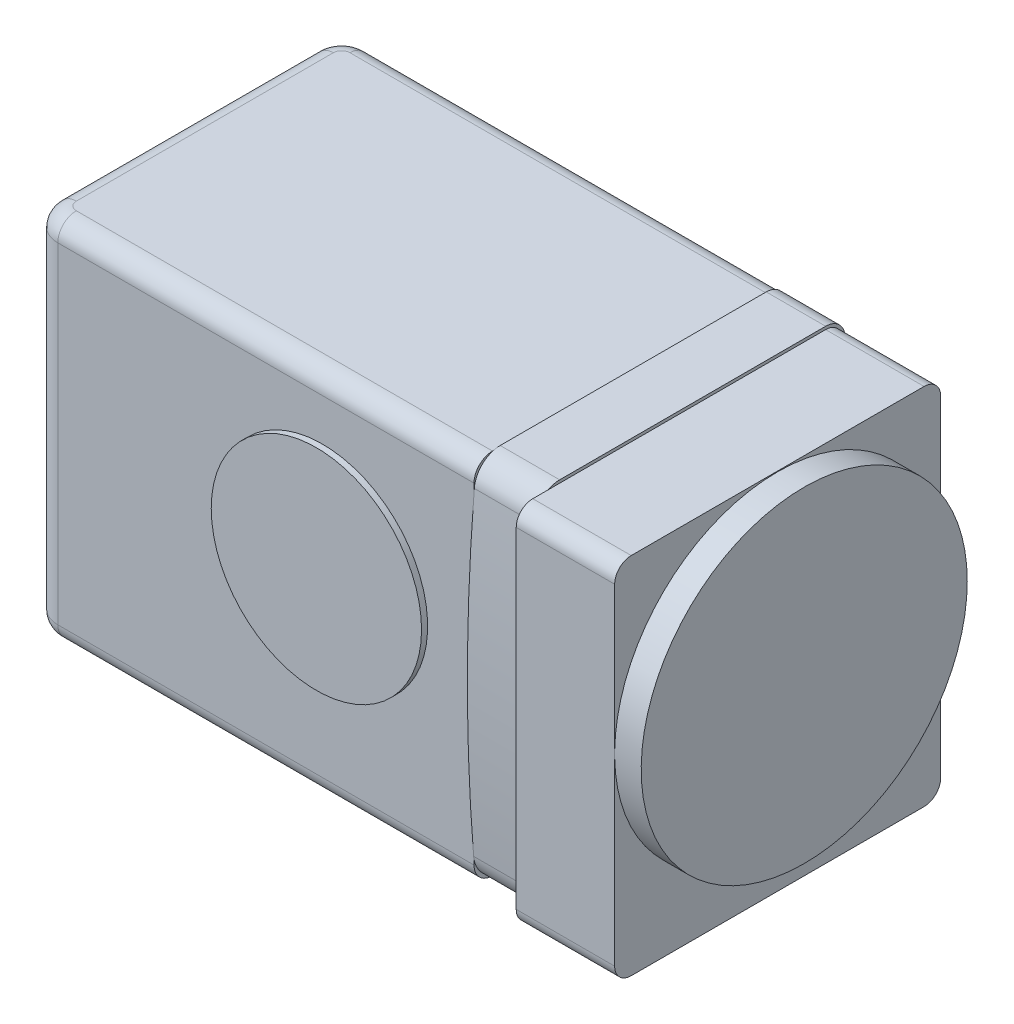
from build123d import *

# Parameters (mm, degrees)
BASE_EXTRUDE_DEPTH      = 43.18
BASE_EXTRUDE_DEPTH_BACK = 52.705
SKETCH5_R               = 27.415532094
BOSS_EXTRUDE1_DEPTH     = 1.5875
SKETCH6_R               = 27.415532094
BOSS_EXTRUDE2_DEPTH     = 0.89408
FILLET1_R               = 4.826
BOSS_EXTRUDE3_DEPTH     = 15.49908
BOSS_EXTRUDE4_DEPTH     = 25.65908
SKETCH9_R               = 42.5
BOSS_EXTRUDE5_DEPTH     = 6.92658


with BuildPart() as part:
    # Sketch4 → Base-Extrude (new body, two sides)
    with BuildSketch(Plane(origin=(0, 0, 0), x_dir=(1, 0, 0), z_dir=(0, 1, 0))) as base_extrude_sk:
        with BuildLine():
            Line((39.5, 43), (-69.000000024, 43))
            ThreePointArc((-69.000000024, 43), (-73.949747477, 40.94974746), (-76, 36))
            Line((-76, 36), (-76, -31))
            ThreePointArc((-76, -31), (-73.949747468, -35.949747468), (-69, -38))
            Line((-69, -38), (39.5, -38))
            Line((39.5, -38), (39.5, 43))
        make_face()
    extrude(amount=BASE_EXTRUDE_DEPTH)
    extrude(base_extrude_sk.sketch, amount=-BASE_EXTRUDE_DEPTH_BACK)

    # Sketch5 → Boss-Extrude1 (add)
    with BuildSketch(Plane.XY.offset(38)):
        with Locations(Location((0, 0, 0), (0, 0, 180))):  # turned: the seam where the file's is
            Circle(SKETCH5_R)
    extrude(amount=BOSS_EXTRUDE1_DEPTH)

    # Sketch6 → Boss-Extrude2 (add)
    with BuildSketch(Plane(origin=(0, 0, -43), x_dir=(-1, 0, 0), z_dir=(0, 0, -1))):
        Circle(SKETCH6_R)
    extrude(amount=BOSS_EXTRUDE2_DEPTH)

    # Fillet1
    fillet1_edges = [part.edges().sort_by_distance(p)[0] for p in [
        (-14.750000012, 43.18, -43),
        (-14.750000012, -52.705, -43),
        (-73.949747477, 43.18, -40.94974746),
        (-76, 43.18, -2.5),
        (-73.949747468, 43.18, 35.949747468),
        (-14.75, 43.18, 38),
        (-73.949747477, -52.705, -40.94974746),
        (-76, -52.705, -2.5),
        (-73.949747468, -52.705, 35.949747468),
        (-14.75, -52.705, 38),
    ]]
    fillet(fillet1_edges, radius=FILLET1_R)

    # Sketch7 → Boss-Extrude3 (add)
    with BuildSketch(Plane(origin=(39.5, 0, 0), x_dir=(0, 0, -1), z_dir=(1, 0, 0))):
        with BuildLine():
            Line((-30.047501034, -52.959), (38.174, -52.959))
            ThreePointArc((38.174, -52.959), (41.766102448, -51.471102448), (43.254, -47.879))
            Line((43.254, -47.879), (43.254, 38.354))
            ThreePointArc((43.254, 38.354), (41.766102448, 41.946102448), (38.174, 43.434))
            Line((38.174, 43.434), (-31.171603367, 43.434))
            ThreePointArc((-31.171603367, 43.434), (-35.785365358, 41.596306208), (-37.915572887, 37.110090199))
            ThreePointArc((-37.915572887, 37.110090199), (-39.734213167, -4.374451524), (-38.091996743, -45.866351694))
            ThreePointArc((-38.091996743, -45.866351694), (-35.500512962, -51.035451283), (-30.047501034, -52.959))
        make_face()
    extrude(amount=BOSS_EXTRUDE3_DEPTH)

    # Sketch8 → Boss-Extrude4 (add)
    with BuildSketch(Plane(origin=(54.99908, 0, 0), x_dir=(0, 0, -1), z_dir=(1, 0, 0))):
        with BuildLine():
            Line((-30.064841666, -52.197), (38.174, -52.197))
            ThreePointArc((38.174, -52.197), (41.227287081, -50.932287081), (42.492, -47.879))
            Line((42.492, -47.879), (42.492, 38.354))
            ThreePointArc((42.492, 38.354), (41.227287081, 41.407287081), (38.174, 42.672))
            Line((38.174, 42.672), (-31.169709456, 42.672))
            Line((-31.169709456, 42.672), (-38.174, 42.672))
            ThreePointArc((-38.174, 42.672), (-41.227287081, 41.407287081), (-42.492, 38.354))
            Line((-42.492, 38.354), (-42.492, -47.879))
            ThreePointArc((-42.492, -47.879), (-41.227287081, -50.932287081), (-38.174, -52.197))
            Line((-38.174, -52.197), (-30.064841666, -52.197))
        make_face()
    extrude(amount=BOSS_EXTRUDE4_DEPTH)

    # Sketch9 → Boss-Extrude5 (add)
    with BuildSketch(Plane(origin=(80.65816, 0, 0), x_dir=(0, 0, -1), z_dir=(1, 0, 0))):
        with Locations(Location((0, 0, 0), (0, 0, 178.888281145))):  # turned: the seam where the file's is
            Circle(SKETCH9_R)
    extrude(amount=BOSS_EXTRUDE5_DEPTH)


solid = part.part
